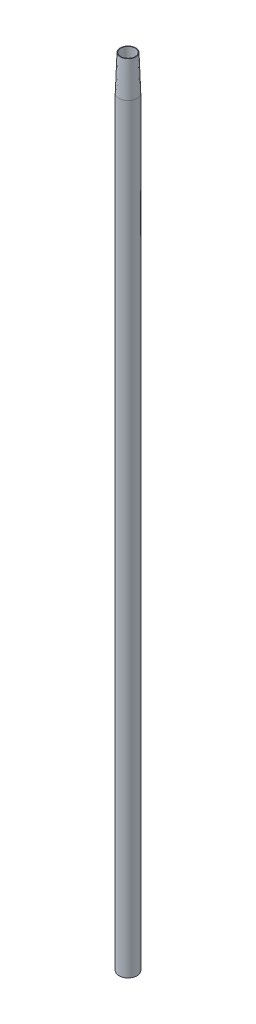
from build123d import *

# Parameters (mm, degrees)
SKETCH1_R           = 2.555
SKETCH1_R_2         = 2.055
BOSS_EXTRUDE1_DEPTH = 225
CHAMFER1_SIZE       = 10
CHAMFER1_SIZE2      = 0.349207695


with BuildPart() as part:
    # Sketch1 → Boss-Extrude1 (new body)
    with BuildSketch(Plane(origin=(0, 0, 0), x_dir=(1, 0, 0), z_dir=(0, 1, 0))):
        Circle(SKETCH1_R)
        Circle(SKETCH1_R_2, mode=Mode.SUBTRACT)
    extrude(amount=BOSS_EXTRUDE1_DEPTH)

    # Chamfer1
    chamfer1_edges = [part.edges().sort_by_distance(p)[0] for p in [
        (-2.555, 225, 0),
    ]]
    chamfer1_side = [part.faces().sort_by_distance(p)[0] for p in [
        (-2.555, 112.5, 0),
    ]]
    chamfer(chamfer1_edges, length=CHAMFER1_SIZE, length2=CHAMFER1_SIZE2, reference=chamfer1_side[0])


solid = part.part
